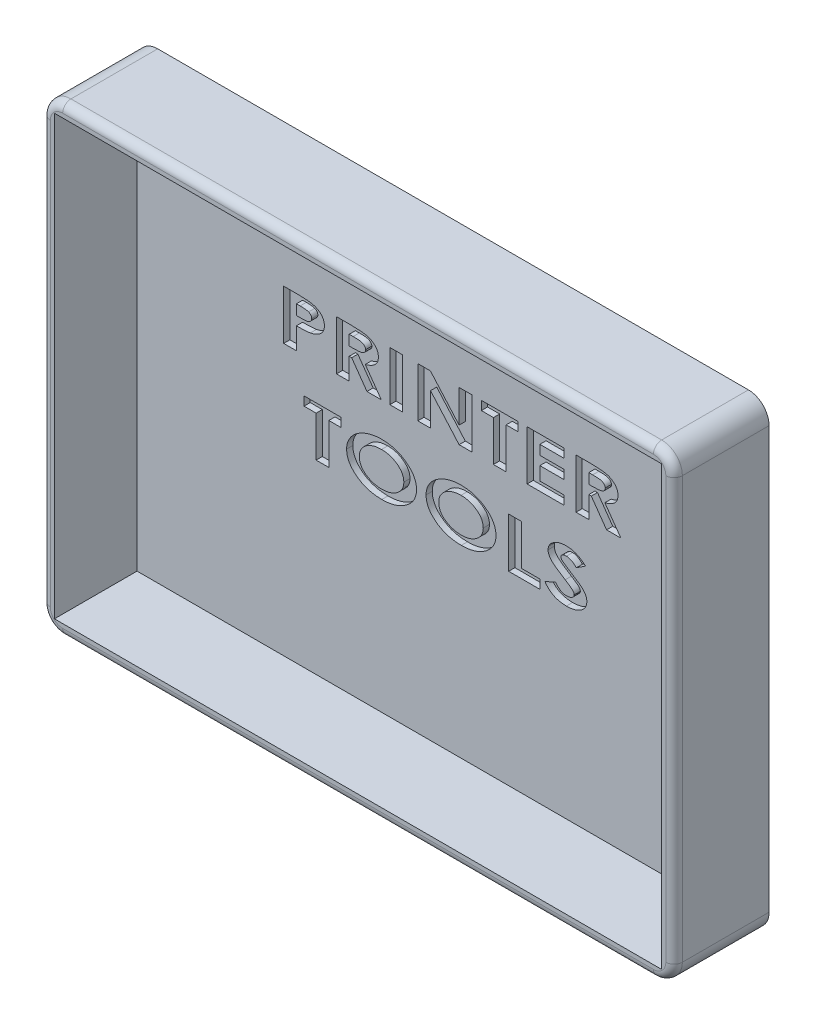
from build123d import *

# Parameters (mm, degrees)
SKETCH1_W           = 153
SKETCH1_H           = 112
BOSS_EXTRUDE1_DEPTH = 3
SKETCH1_3_W         = 153
SKETCH1_3_H         = 112
SKETCH1_3_W_2       = 147
SKETCH1_3_H_2       = 106
BOSS_EXTRUDE2_DEPTH = 23
FILLET2_R           = 5
SKETCH2_W           = 3.076923077
SKETCH2_H           = 12
CUT_EXTRUDE1_DEPTH  = 1.5
FILLET3_R           = 2


with BuildPart() as part:
    # Sketch1 → Boss-Extrude1 (new body)
    with BuildSketch(Plane.XY):
        with Locations((30.305422648, -30.684210526)):
            Rectangle(SKETCH1_W, SKETCH1_H)
    extrude(amount=BOSS_EXTRUDE1_DEPTH)

    # Sketch1_3 → Boss-Extrude2 (add)
    with BuildSketch(Plane.XY):
        with Locations((30.305422648, -30.684210526)):
            Rectangle(SKETCH1_3_W, SKETCH1_3_H)
        with Locations((30.305422648, -30.684210526)):
            Rectangle(SKETCH1_3_W_2, SKETCH1_3_H_2, mode=Mode.SUBTRACT)
    extrude(amount=BOSS_EXTRUDE2_DEPTH)

    # Fillet2
    fillet2_edges = [part.edges().sort_by_distance(p)[0] for p in [
        (-46.194577352, -86.684210526, 11.5),
        (106.805422648, -86.684210526, 11.5),
        (106.805422648, 25.315789474, 11.5),
        (-46.194577352, 25.315789474, 11.5),
    ]]
    fillet(fillet2_edges, radius=FILLET2_R)

    # Sketch2 → Cut-Extrude1 (cut)
    # profile 1 of 12: a face of its own
    with BuildSketch(Plane.XY.offset(3)):
        with BuildLine():
            Line((-7.695579614, -6.197177574), (-4.349425768, -6.197177574))
            add(Edge.make_bspline(
                [(-4.349425768, -6.197177574), (-4.131467614, -6.197879272), (-3.710704223, -6.199233883), (-3.103144005, -6.215737304), (-2.542184607, -6.245066636), (-2.028928537, -6.281485518), (-1.563280857, -6.332664074), (-1.145069661, -6.390836776), (-0.773328843, -6.462155499), (-0.443402082, -6.546890093), (-0.145691957, -6.645697252), (0.13296354, -6.75186301), (0.391506905, -6.879711466), (0.639402349, -7.011764168), (0.867025458, -7.165496853), (1.082376086, -7.327943018), (1.280194507, -7.506561053), (1.460170342, -7.699443536), (1.623579223, -7.901540289), (1.764138864, -8.116214552), (1.885557013, -8.338851141), (1.980483241, -8.57435743), (2.059592806, -8.817132684), (2.110378509, -9.072176501), (2.14653073, -9.335561495), (2.149217666, -9.515157797), (2.150574232, -9.605831421)],
                knots=[0, 0, 0, 0, 1.900234888, 3.668361378, 5.29824944, 6.797419469, 8.153669347, 9.381710471, 10.477773137, 11.452059101, 12.348987854, 13.211691364, 14.049075643, 14.861973494, 15.658312658, 16.440772353, 17.212397831, 17.97846912, 18.738913567, 19.475196238, 20.212836479, 20.945830748, 21.685980875, 22.435435663, 23.210091095, 24, 24, 24, 24], degree=3))
            add(Edge.make_bspline(
                [(2.150574232, -9.605831421), (2.147867067, -9.706142994), (2.14253497, -9.903719033), (2.098514921, -10.193181857), (2.025408944, -10.469052156), (1.927374553, -10.733721068), (1.796727947, -10.984401602), (1.635891414, -11.220560789), (1.450806817, -11.446839604), (1.232122761, -11.654005562), (0.993171391, -11.850703825), (0.732492987, -12.031275679), (0.451674064, -12.195227151), (0.150370942, -12.344333507), (-0.171973476, -12.478137466), (-0.514236551, -12.59900067), (-0.877154686, -12.702489054), (-1.127929291, -12.756302871), (-1.255675768, -12.783716036)],
                knots=[0, 0, 0, 0, 0.947754169, 1.866718941, 2.759471002, 3.641428849, 4.528897163, 5.423702711, 6.338100003, 7.286096209, 8.26548705, 9.261284238, 10.279606345, 11.336321123, 12.436199946, 13.576329595, 14.765363998, 16, 16, 16, 16], degree=3))
            add(Edge.make_bspline(
                [(-1.255675768, -12.783716036), (-1.340477898, -12.799027687), (-1.524578479, -12.832268408), (-1.827368136, -12.865930289), (-2.176819972, -12.896773674), (-2.573515238, -12.923387066), (-3.017588279, -12.941492092), (-3.508811633, -12.955576697), (-4.048101182, -12.965867911), (-4.42313843, -12.966223148), (-4.618656537, -12.966408344)],
                knots=[0, 0, 0, 0, 0.613221355, 1.331268544, 2.167268072, 3.11042782, 4.160855784, 5.330565642, 6.608344223, 8, 8, 8, 8], degree=3))
            Line((-4.618656537, -12.966408344), (-4.618656537, -18.197177574))
            Line((-4.618656537, -18.197177574), (-7.695579614, -18.197177574))
            Line((-7.695579614, -18.197177574), (-7.695579614, -6.197177574))
        make_face()
        with BuildLine():
            Line((-4.618656537, -10.81256219), (-3.601829614, -10.81256219))
            add(Edge.make_bspline(
                [(-3.601829614, -10.81256219), (-3.505674623, -10.81190457), (-3.320564917, -10.810638575), (-3.054482429, -10.806522541), (-2.810794726, -10.797259626), (-2.591280496, -10.782388183), (-2.393910615, -10.766556965), (-2.220093442, -10.744477948), (-2.068075558, -10.722000712), (-1.900023268, -10.68381989), (-1.71561963, -10.623717561), (-1.516550116, -10.532578797), (-1.341649369, -10.422057161), (-1.192825623, -10.291539877), (-1.073675701, -10.142147718), (-0.988040191, -9.97559123), (-0.935356602, -9.794087059), (-0.929394202, -9.667886041), (-0.926348845, -9.603427574)],
                knots=[0, 0, 0, 0, 1.407605413, 2.709806541, 3.895428679, 4.976847854, 5.930489772, 6.793236331, 7.541454841, 8.178861105, 9.313911922, 10.374001262, 11.376181959, 12.331769573, 13.258707867, 14.155775968, 15.058043621, 16, 16, 16, 16], degree=3))
            add(Edge.make_bspline(
                [(-0.926348845, -9.603427574), (-0.928471644, -9.54711837), (-0.932612279, -9.437284214), (-0.970356718, -9.279286589), (-1.028595595, -9.132252483), (-1.110291405, -8.995622574), (-1.221245851, -8.875329604), (-1.35317864, -8.767095415), (-1.505363324, -8.665633721), (-1.620916995, -8.615263243), (-1.681156537, -8.589004497)],
                knots=[0, 0, 0, 0, 0.99967641, 1.949923027, 2.870450112, 3.803674722, 4.761895576, 5.763194509, 6.833925937, 8, 8, 8, 8], degree=3))
            add(Edge.make_bspline(
                [(-1.681156537, -8.589004497), (-1.731324429, -8.569628601), (-1.839554677, -8.527827799), (-2.021902872, -8.481533475), (-2.232300183, -8.441595142), (-2.472190478, -8.408067498), (-2.740886636, -8.382577432), (-3.039863219, -8.362761379), (-3.36781756, -8.354968555), (-3.596220318, -8.352371933), (-3.714810383, -8.351023728)],
                knots=[0, 0, 0, 0, 0.626672195, 1.351958081, 2.189428709, 3.123683958, 4.175242118, 5.336301276, 6.616968516, 8, 8, 8, 8], degree=3))
            Line((-3.714810383, -8.351023728), (-4.618656537, -8.351023728))
            Line((-4.618656537, -8.351023728), (-4.618656537, -10.81256219))
        make_face(mode=Mode.SUBTRACT)
    # profile 2 of 12: a face of its own
    with BuildSketch(Plane.XY.offset(3)):
        with BuildLine():
            Line((5.073651155, -6.197177574), (8.523170386, -6.197177574))
            add(Edge.make_bspline(
                [(8.523170386, -6.197177574), (8.750747746, -6.197791838), (9.189944995, -6.198977293), (9.822245411, -6.216587639), (10.404198058, -6.241837818), (10.934173925, -6.279274779), (11.414294904, -6.3299995), (11.84268897, -6.388597237), (12.221011719, -6.457127557), (12.553307177, -6.539597912), (12.853071694, -6.635819066), (13.132155907, -6.743071681), (13.395730781, -6.867200625), (13.645754459, -7.002715932), (13.88005405, -7.156183599), (14.101589864, -7.320642176), (14.306444855, -7.502497062), (14.496393324, -7.695965049), (14.666159414, -7.902339724), (14.817489389, -8.117536414), (14.944317635, -8.343139895), (15.049149765, -8.577855957), (15.12798197, -8.822345423), (15.186136709, -9.074740371), (15.220302505, -9.337270963), (15.225068935, -9.51518749), (15.227497309, -9.605831421)],
                knots=[0, 0, 0, 0, 1.942360821, 3.748525479, 5.398471571, 6.913875045, 8.282418781, 9.518505043, 10.603687565, 11.562434919, 12.438404284, 13.289346962, 14.112375837, 14.923468866, 15.714505135, 16.50100498, 17.276273883, 18.050093459, 18.812802014, 19.554618987, 20.292643093, 21.018300149, 21.744987786, 22.48161628, 23.226422243, 24, 24, 24, 24], degree=3))
            add(Edge.make_bspline(
                [(15.227497309, -9.605831421), (15.225573315, -9.700544367), (15.221790142, -9.886779562), (15.180516871, -10.159143314), (15.122397007, -10.420785255), (15.034552049, -10.67051461), (14.921479656, -10.907565453), (14.785335619, -11.134301168), (14.624537546, -11.348132952), (14.436590288, -11.548176294), (14.227969781, -11.739725288), (13.98926994, -11.914577474), (13.72869362, -12.080069114), (13.441297744, -12.232366032), (13.130259804, -12.372724383), (12.794193473, -12.503125017), (12.433103425, -12.621235868), (12.181397835, -12.687272166), (12.05201654, -12.721216036)],
                knots=[0, 0, 0, 0, 0.938261817, 1.844915378, 2.725580461, 3.592377074, 4.462987792, 5.325404772, 6.21039484, 7.109815044, 8.043390327, 9.01418199, 10.039020095, 11.101679491, 12.235815788, 13.420467275, 14.674072806, 16, 16, 16, 16], degree=3))
            Line((12.05201654, -12.721216036), (15.919805001, -18.197177574))
            Line((15.919805001, -18.197177574), (12.45826654, -18.197177574))
            Line((12.45826654, -18.197177574), (8.763555001, -12.966408344))
            Line((8.763555001, -12.966408344), (8.150574232, -12.966408344))
            Line((8.150574232, -12.966408344), (8.150574232, -18.197177574))
            Line((8.150574232, -18.197177574), (5.073651155, -18.197177574))
            Line((5.073651155, -18.197177574), (5.073651155, -6.197177574))
        make_face()
        with BuildLine():
            Line((8.150574232, -10.81256219), (9.23951654, -10.81256219))
            add(Edge.make_bspline(
                [(9.23951654, -10.81256219), (9.372531557, -10.811391488), (9.628201298, -10.809141269), (9.995495867, -10.799031275), (10.329710072, -10.774191883), (10.631112904, -10.743044672), (10.901353531, -10.706992837), (11.138617554, -10.655935328), (11.345067184, -10.599783582), (11.520849134, -10.532313803), (11.670876876, -10.454106745), (11.799967238, -10.365862854), (11.906982056, -10.26229608), (11.99797672, -10.149816306), (12.06484483, -10.021599637), (12.116430185, -9.884788226), (12.145525221, -9.734440986), (12.148848811, -9.630793321), (12.150574232, -9.576985267)],
                knots=[0, 0, 0, 0, 1.810256827, 3.479516111, 4.999140943, 6.369538748, 7.603227407, 8.706779841, 9.669889474, 10.512282949, 11.263419155, 11.968249844, 12.631536789, 13.283796803, 13.92780119, 14.590191195, 15.26810634, 16, 16, 16, 16], degree=3))
            add(Edge.make_bspline(
                [(12.150574232, -9.576985267), (12.146934721, -9.513266081), (12.139729467, -9.387119225), (12.079850272, -9.204648904), (11.977294657, -9.039151196), (11.841577785, -8.886809693), (11.671922737, -8.753586805), (11.476344592, -8.6379508), (11.254154619, -8.543636331), (11.04774873, -8.483925714), (10.858680195, -8.447132546), (10.687997821, -8.420391064), (10.490511398, -8.40022932), (10.266226497, -8.38020044), (10.014478821, -8.366596105), (9.735580177, -8.356991674), (9.429431164, -8.352946507), (9.216279633, -8.351683625), (9.104901155, -8.351023728)],
                knots=[0, 0, 0, 0, 0.842981993, 1.668877706, 2.511859699, 3.406725258, 4.358415719, 5.357990113, 6.409063649, 7.547987131, 8.197583625, 8.96033808, 9.836107581, 10.827075533, 11.943612093, 13.175842126, 14.52428738, 16, 16, 16, 16], degree=3))
            Line((9.104901155, -8.351023728), (8.150574232, -8.351023728))
            Line((8.150574232, -8.351023728), (8.150574232, -10.81256219))
        make_face(mode=Mode.SUBTRACT)
    # profile 3 of 12: a face of its own
    with BuildSketch(Plane.XY.offset(3)):
        with Locations((19.535189616, -12.197177574)):
            Rectangle(SKETCH2_W, SKETCH2_H)
    # profile 4 of 12: a face of its own
    with BuildSketch(Plane.XY.offset(3)):
        Polygon((24.765958848, -6.197177574), (27.828458848, -6.197177574), (34.765958848, -14.09381219), (34.765958848, -6.197177574), (37.842881924, -6.197177574), (37.842881924, -18.197177574), (34.761151155, -18.197177574), (27.842881924, -10.324581421), (27.842881924, -18.197177574), (24.765958848, -18.197177574), align=None)
    # profile 5 of 12: a face of its own
    with BuildSketch(Plane.XY.offset(3)):
        Polygon((40.150574232, -6.197177574), (49.073651155, -6.197177574), (49.073651155, -8.351023728), (46.150574232, -8.351023728), (46.150574232, -18.197177574), (43.073651155, -18.197177574), (43.073651155, -8.351023728), (40.150574232, -8.351023728), align=None)
    # profile 6 of 12: a face of its own
    with BuildSketch(Plane.XY.offset(3)):
        Polygon((51.227497309, -6.197177574), (60.150574232, -6.197177574), (60.150574232, -8.351023728), (54.304420386, -8.351023728), (54.304420386, -10.658716036), (60.150574232, -10.658716036), (60.150574232, -12.81256219), (54.304420386, -12.81256219), (54.304420386, -16.043331421), (60.150574232, -16.043331421), (60.150574232, -18.197177574), (51.227497309, -18.197177574), align=None)
    # profile 7 of 12: a face of its own
    with BuildSketch(Plane.XY.offset(3)):
        with BuildLine():
            Line((63.073651155, -6.197177574), (66.523170386, -6.197177574))
            add(Edge.make_bspline(
                [(66.523170386, -6.197177574), (66.750747746, -6.197791838), (67.189944995, -6.198977293), (67.822245411, -6.216587639), (68.404198058, -6.241837818), (68.934173925, -6.279274779), (69.414294904, -6.3299995), (69.84268897, -6.388597237), (70.221011719, -6.457127557), (70.553307177, -6.539597912), (70.853071694, -6.635819066), (71.132155907, -6.743071681), (71.395730781, -6.867200625), (71.645754459, -7.002715932), (71.88005405, -7.156183599), (72.101589864, -7.320642176), (72.306444855, -7.502497062), (72.496393324, -7.695965049), (72.666159414, -7.902339724), (72.817489389, -8.117536414), (72.944317635, -8.343139895), (73.049149765, -8.577855957), (73.12798197, -8.822345423), (73.186136709, -9.074740371), (73.220302505, -9.337270963), (73.225068935, -9.51518749), (73.227497309, -9.605831421)],
                knots=[0, 0, 0, 0, 1.942360821, 3.748525479, 5.398471571, 6.913875045, 8.282418781, 9.518505043, 10.603687565, 11.562434919, 12.438404284, 13.289346962, 14.112375837, 14.923468866, 15.714505135, 16.50100498, 17.276273883, 18.050093459, 18.812802014, 19.554618987, 20.292643093, 21.018300149, 21.744987786, 22.48161628, 23.226422243, 24, 24, 24, 24], degree=3))
            add(Edge.make_bspline(
                [(73.227497309, -9.605831421), (73.225573315, -9.700544367), (73.221790142, -9.886779562), (73.180516871, -10.159143314), (73.122397007, -10.420785255), (73.034552049, -10.67051461), (72.921479656, -10.907565453), (72.785335619, -11.134301168), (72.624537546, -11.348132952), (72.436590288, -11.548176294), (72.227969781, -11.739725288), (71.98926994, -11.914577474), (71.72869362, -12.080069114), (71.441297744, -12.232366032), (71.130259804, -12.372724383), (70.794193473, -12.503125017), (70.433103425, -12.621235868), (70.181397835, -12.687272166), (70.05201654, -12.721216036)],
                knots=[0, 0, 0, 0, 0.938261817, 1.844915378, 2.725580461, 3.592377074, 4.462987792, 5.325404772, 6.21039484, 7.109815044, 8.043390327, 9.01418199, 10.039020095, 11.101679491, 12.235815788, 13.420467275, 14.674072806, 16, 16, 16, 16], degree=3))
            Line((70.05201654, -12.721216036), (73.919805001, -18.197177574))
            Line((73.919805001, -18.197177574), (70.45826654, -18.197177574))
            Line((70.45826654, -18.197177574), (66.763555001, -12.966408344))
            Line((66.763555001, -12.966408344), (66.150574232, -12.966408344))
            Line((66.150574232, -12.966408344), (66.150574232, -18.197177574))
            Line((66.150574232, -18.197177574), (63.073651155, -18.197177574))
            Line((63.073651155, -18.197177574), (63.073651155, -6.197177574))
        make_face()
        with BuildLine():
            Line((66.150574232, -10.81256219), (67.23951654, -10.81256219))
            add(Edge.make_bspline(
                [(67.23951654, -10.81256219), (67.372531557, -10.811391488), (67.628201298, -10.809141269), (67.995495867, -10.799031275), (68.329710072, -10.774191883), (68.631112904, -10.743044672), (68.901353531, -10.706992837), (69.138617554, -10.655935328), (69.345067184, -10.599783582), (69.520849134, -10.532313803), (69.670876876, -10.454106745), (69.799967238, -10.365862854), (69.906982056, -10.26229608), (69.99797672, -10.149816306), (70.06484483, -10.021599637), (70.116430185, -9.884788226), (70.145525221, -9.734440986), (70.148848811, -9.630793321), (70.150574232, -9.576985267)],
                knots=[0, 0, 0, 0, 1.810256827, 3.479516111, 4.999140943, 6.369538748, 7.603227407, 8.706779841, 9.669889474, 10.512282949, 11.263419155, 11.968249844, 12.631536789, 13.283796803, 13.92780119, 14.590191195, 15.26810634, 16, 16, 16, 16], degree=3))
            add(Edge.make_bspline(
                [(70.150574232, -9.576985267), (70.146934721, -9.513266081), (70.139729467, -9.387119225), (70.079850272, -9.204648904), (69.977294657, -9.039151196), (69.841577785, -8.886809693), (69.671922737, -8.753586805), (69.476344592, -8.6379508), (69.254154619, -8.543636331), (69.04774873, -8.483925714), (68.858680195, -8.447132546), (68.687997821, -8.420391064), (68.490511398, -8.40022932), (68.266226497, -8.38020044), (68.014478821, -8.366596105), (67.735580177, -8.356991674), (67.429431164, -8.352946507), (67.216279633, -8.351683625), (67.104901155, -8.351023728)],
                knots=[0, 0, 0, 0, 0.842981993, 1.668877706, 2.511859699, 3.406725258, 4.358415719, 5.357990113, 6.409063649, 7.547987131, 8.197583625, 8.96033808, 9.836107581, 10.827075533, 11.943612093, 13.175842126, 14.52428738, 16, 16, 16, 16], degree=3))
            Line((67.104901155, -8.351023728), (66.150574232, -8.351023728))
            Line((66.150574232, -8.351023728), (66.150574232, -10.81256219))
        make_face(mode=Mode.SUBTRACT)
    # profile 8 of 12: a face of its own
    with BuildSketch(Plane.XY.offset(3)):
        Polygon((-2.772502691, -26.735639113), (6.150574232, -26.735639113), (6.150574232, -28.889485267), (3.227497309, -28.889485267), (3.227497309, -38.735639113), (0.150574232, -38.735639113), (0.150574232, -28.889485267), (-2.772502691, -28.889485267), align=None)
    # profile 9 of 12: a face of its own
    with BuildSketch(Plane.XY.offset(3)):
        with BuildLine():
            add(Edge.make_bspline(
                [(16.030381924, -26.427946805), (16.313464778, -26.433281266), (16.870571184, -26.443779472), (17.690963054, -26.5329144), (18.481204957, -26.675715702), (19.241728769, -26.878399254), (19.972107481, -27.138030614), (20.671919756, -27.45627568), (21.340498516, -27.833436075), (21.869213507, -28.192318047), (22.270223583, -28.503427209), (22.553061142, -28.742643209), (22.817568613, -28.98847452), (23.058165861, -29.24357625), (23.284960994, -29.50105028), (23.487793817, -29.768178464), (23.674085875, -30.03914507), (23.83831577, -30.318428594), (23.984650192, -30.602122767), (24.110273204, -30.894070572), (24.219263457, -31.190423495), (24.304606965, -31.495567081), (24.375906418, -31.804798328), (24.422896601, -32.121509006), (24.452916801, -32.444187071), (24.456472288, -32.661853115), (24.45826654, -32.771696805)],
                knots=[0, 0, 0, 0, 1.745145968, 3.434443253, 5.081950776, 6.692722788, 8.282073641, 9.856384965, 11.427133449, 13.009958241, 13.791714529, 14.555942899, 15.293528752, 16.016945007, 16.717403943, 17.408176707, 18.083798791, 18.743904067, 19.404619276, 20.050801644, 20.702570137, 21.350035736, 22.003319428, 22.658077529, 23.322807938, 24, 24, 24, 24], degree=3))
            add(Edge.make_bspline(
                [(24.45826654, -32.771696805), (24.456431295, -32.879933089), (24.452781447, -33.095188341), (24.4231306, -33.41473388), (24.375076142, -33.728632526), (24.307854016, -34.036194142), (24.221500795, -34.337470758), (24.11412709, -34.631247779), (23.993010172, -34.920914226), (23.847646653, -35.202081437), (23.68321935, -35.476968838), (23.501027681, -35.74648464), (23.297437111, -36.007995723), (23.079325664, -36.266954139), (22.83820868, -36.516378949), (22.577499668, -36.758431505), (22.301189718, -36.998262679), (21.904185796, -37.303552621), (21.380308733, -37.657536546), (20.717030226, -38.030199798), (20.018899219, -38.342797499), (19.289070242, -38.600626648), (18.525976508, -38.800505741), (17.730155684, -38.941290676), (16.901648051, -39.026773345), (16.338279239, -39.037752579), (16.05201654, -39.043331421)],
                knots=[0, 0, 0, 0, 0.67051785, 1.33349449, 1.986488314, 2.636986177, 3.282787654, 3.926658881, 4.573985186, 5.226771377, 5.885776778, 6.557745033, 7.240935207, 7.938283214, 8.654566243, 9.388675605, 10.142022968, 10.920566582, 12.49030535, 14.055074537, 15.628326538, 17.223646782, 18.845680182, 20.509983457, 22.226629637, 24, 24, 24, 24], degree=3))
            add(Edge.make_bspline(
                [(16.05201654, -39.043331421), (15.900544408, -39.042015286), (15.601449642, -39.039416466), (15.157333914, -39.016639141), (14.723299595, -38.982352438), (14.29878103, -38.927388005), (13.883924116, -38.864043877), (13.477972734, -38.784508352), (13.082635251, -38.688734428), (12.697468317, -38.5770564), (12.320533169, -38.455261382), (11.954110932, -38.315998386), (11.597350632, -38.161644366), (11.250736639, -37.993412074), (10.913535786, -37.80973356), (10.584592343, -37.613892777), (10.266598213, -37.40136395), (9.960618094, -37.176285062), (9.667798131, -36.942271246), (9.394229627, -36.698316612), (9.136411199, -36.45244259), (8.89981289, -36.198008763), (8.681160711, -35.939215208), (8.481182038, -35.674490538), (8.300524533, -35.404880429), (8.138302401, -35.130007259), (7.996841722, -34.848669565), (7.873598445, -34.562209481), (7.770696499, -34.270298441), (7.683149261, -33.973801893), (7.615209749, -33.671189819), (7.571334787, -33.362408064), (7.540351627, -33.048765672), (7.536921163, -32.837479417), (7.535189617, -32.730831421)],
                knots=[0, 0, 0, 0, 1.23785739, 2.444256004, 3.633631352, 4.795169465, 5.941806634, 7.063009603, 8.174840564, 9.265073711, 10.339876336, 11.411402117, 12.467345856, 13.515871935, 14.559067395, 15.604664997, 16.643576268, 17.683560242, 18.708340531, 19.705742031, 20.67834854, 21.618923025, 22.543772652, 23.446185256, 24.32889845, 25.1948367, 26.05293937, 26.900785464, 27.741724346, 28.581004192, 29.426266696, 30.273682739, 31.128631069, 32, 32, 32, 32], degree=3))
            add(Edge.make_bspline(
                [(7.535189617, -32.730831421), (7.538218692, -32.588838737), (7.544246865, -32.30625862), (7.59903142, -31.887159115), (7.687503626, -31.476781898), (7.814199881, -31.076066737), (7.973004646, -30.683680124), (8.166138604, -30.298534378), (8.39810017, -29.924345425), (8.662928876, -29.55927496), (8.956548652, -29.207129875), (9.281254584, -28.874722628), (9.629819601, -28.559158128), (10.005841321, -28.263005687), (10.409082755, -27.986854231), (10.83639334, -27.726098054), (11.293114556, -27.489182168), (11.771767827, -27.268783692), (12.267966627, -27.069972998), (12.77821213, -26.899772162), (13.296543007, -26.75149063), (13.826179081, -26.636045258), (14.363026135, -26.539678598), (14.910674039, -26.477344547), (15.46716189, -26.433411743), (15.841992403, -26.429774753), (16.030381924, -26.427946805)],
                knots=[0, 0, 0, 0, 0.873545157, 1.738445156, 2.596414495, 3.454256273, 4.321472879, 5.199225574, 6.102525423, 7.027795969, 7.97301071, 8.9215899, 9.885252081, 10.86491977, 11.864845162, 12.891577554, 13.943741457, 15.029372765, 16.133759519, 17.231619976, 18.338470262, 19.449968713, 20.566368297, 21.693693259, 22.840852048, 24, 24, 24, 24], degree=3))
        make_face()
        with BuildLine():
            add(Edge.make_bspline(
                [(15.984708848, -28.581792959), (15.798664494, -28.585484814), (15.433748369, -28.592726192), (14.897931864, -28.649692853), (14.383981684, -28.739545725), (13.892808566, -28.869655269), (13.42418118, -29.036295377), (12.977399751, -29.237527466), (12.555449674, -29.480237743), (12.158525109, -29.753754529), (11.797667104, -30.056896154), (11.478669015, -30.381468598), (11.214337738, -30.730826295), (10.990837574, -31.095171308), (10.822848879, -31.484404984), (10.699361714, -31.89130087), (10.625335191, -32.319492029), (10.616574228, -32.611150206), (10.612112694, -32.759677574)],
                knots=[0, 0, 0, 0, 1.177915509, 2.310418757, 3.408289834, 4.479079589, 5.523885619, 6.554848934, 7.57758788, 8.602288603, 9.603464323, 10.55798171, 11.477463708, 12.372050713, 13.258222719, 14.153960245, 15.059901456, 16, 16, 16, 16], degree=3))
            add(Edge.make_bspline(
                [(10.612112694, -32.759677574), (10.618067804, -32.924382439), (10.629782516, -33.248384868), (10.723711871, -33.719983827), (10.875125811, -34.165928341), (11.093285608, -34.582900519), (11.368526149, -34.975968487), (11.710414375, -35.337174585), (12.10900324, -35.674682905), (12.409353971, -35.867240454), (12.564035771, -35.966408344)],
                knots=[0, 0, 0, 0, 1.002378203, 1.971848096, 2.916297197, 3.86133863, 4.827991989, 5.829253018, 6.882056827, 8, 8, 8, 8], degree=3))
            add(Edge.make_bspline(
                [(12.564035771, -35.966408344), (12.691121383, -36.040628983), (12.945806324, -36.189370281), (13.348271744, -36.374528715), (13.763078942, -36.53460972), (14.192221937, -36.664338114), (14.634860942, -36.765125226), (15.091776278, -36.837186599), (15.562358019, -36.881359014), (15.88124752, -36.88675723), (16.042401155, -36.889485267)],
                knots=[0, 0, 0, 0, 0.968643878, 1.941203282, 2.913290218, 3.894783287, 4.890638372, 5.900389362, 6.938943154, 8, 8, 8, 8], degree=3))
            add(Edge.make_bspline(
                [(16.042401155, -36.889485267), (16.223622619, -36.885663384), (16.580510815, -36.878136765), (17.105510693, -36.822524238), (17.60998348, -36.728178372), (18.094591068, -36.599355349), (18.558111965, -36.430701449), (18.999764687, -36.222423419), (19.421792613, -35.978660933), (19.820392002, -35.702976267), (20.184284806, -35.397948228), (20.502400908, -35.07022298), (20.775617275, -34.727033751), (20.998114189, -34.364924313), (21.171777987, -33.984080387), (21.289627031, -33.584823761), (21.369108379, -33.169869126), (21.377223027, -32.886658573), (21.381343463, -32.742850651)],
                knots=[0, 0, 0, 0, 1.159372101, 2.283207576, 3.373194553, 4.440212365, 5.487928247, 6.524559945, 7.560443406, 8.602890401, 9.621657833, 10.593309606, 11.520501184, 12.422635105, 13.306015146, 14.189915719, 15.080880085, 16, 16, 16, 16], degree=3))
            add(Edge.make_bspline(
                [(21.381343463, -32.742850651), (21.377086026, -32.599876429), (21.368678457, -32.317531558), (21.290800583, -31.903475326), (21.16812403, -31.506260833), (20.995998697, -31.125489667), (20.772518474, -30.762572189), (20.498305562, -30.417984647), (20.176313602, -30.090048861), (19.810104827, -29.782999995), (19.410202056, -29.501167176), (18.98267574, -29.256573832), (18.536474662, -29.04409342), (18.065839087, -28.877955483), (17.575734725, -28.745041421), (17.064821348, -28.64823004), (16.531600093, -28.593204661), (16.16912827, -28.585641146), (15.984708848, -28.581792959)],
                knots=[0, 0, 0, 0, 0.90719629, 1.791527272, 2.665475917, 3.542279041, 4.437696418, 5.365131948, 6.333100567, 7.351453338, 8.396138617, 9.435668054, 10.475956939, 11.53022765, 12.60045266, 13.698266854, 14.828917806, 16, 16, 16, 16], degree=3))
        make_face(mode=Mode.SUBTRACT)
    # profile 10 of 12: a face of its own
    with BuildSketch(Plane.XY.offset(3)):
        with BuildLine():
            add(Edge.make_bspline(
                [(35.261151155, -26.427946805), (35.544234009, -26.433281266), (36.101340414, -26.443779472), (36.921732285, -26.5329144), (37.711974187, -26.675715702), (38.472498, -26.878399254), (39.202876712, -27.138030614), (39.902688987, -27.45627568), (40.571267747, -27.833436075), (41.099982738, -28.192318047), (41.500992813, -28.503427209), (41.783830372, -28.742643209), (42.048337844, -28.98847452), (42.288935092, -29.24357625), (42.515730225, -29.50105028), (42.718563048, -29.768178464), (42.904855106, -30.03914507), (43.069085, -30.318428594), (43.215419423, -30.602122767), (43.341042435, -30.894070572), (43.450032687, -31.190423495), (43.535376196, -31.495567081), (43.606675649, -31.804798328), (43.653665831, -32.121509006), (43.683686031, -32.444187071), (43.687241518, -32.661853115), (43.689035771, -32.771696805)],
                knots=[0, 0, 0, 0, 1.745145968, 3.434443253, 5.081950776, 6.692722788, 8.282073641, 9.856384965, 11.427133449, 13.009958241, 13.791714529, 14.555942899, 15.293528752, 16.016945007, 16.717403943, 17.408176707, 18.083798791, 18.743904067, 19.404619276, 20.050801644, 20.702570137, 21.350035736, 22.003319428, 22.658077529, 23.322807938, 24, 24, 24, 24], degree=3))
            add(Edge.make_bspline(
                [(43.689035771, -32.771696805), (43.687200526, -32.879933089), (43.683550678, -33.095188341), (43.653899831, -33.41473388), (43.605845373, -33.728632526), (43.538623247, -34.036194142), (43.452270026, -34.337470758), (43.344896321, -34.631247779), (43.223779403, -34.920914226), (43.078415884, -35.202081437), (42.913988581, -35.476968838), (42.731796912, -35.74648464), (42.528206342, -36.007995723), (42.310094895, -36.266954139), (42.068977911, -36.516378949), (41.808268899, -36.758431505), (41.531958949, -36.998262679), (41.134955027, -37.303552621), (40.611077964, -37.657536546), (39.947799456, -38.030199798), (39.24966845, -38.342797499), (38.519839473, -38.600626648), (37.756745739, -38.800505741), (36.960924915, -38.941290676), (36.132417281, -39.026773345), (35.56904847, -39.037752579), (35.282785771, -39.043331421)],
                knots=[0, 0, 0, 0, 0.67051785, 1.33349449, 1.986488314, 2.636986177, 3.282787654, 3.926658881, 4.573985186, 5.226771377, 5.885776778, 6.557745033, 7.240935207, 7.938283214, 8.654566243, 9.388675605, 10.142022968, 10.920566582, 12.49030535, 14.055074537, 15.628326538, 17.223646782, 18.845680182, 20.509983457, 22.226629637, 24, 24, 24, 24], degree=3))
            add(Edge.make_bspline(
                [(35.282785771, -39.043331421), (35.131313639, -39.042015286), (34.832218873, -39.039416466), (34.388103144, -39.016639141), (33.954068825, -38.982352438), (33.529550261, -38.927388005), (33.114693347, -38.864043877), (32.708741965, -38.784508352), (32.313404481, -38.688734428), (31.928237547, -38.5770564), (31.5513024, -38.455261382), (31.184880163, -38.315998386), (30.828119862, -38.161644366), (30.48150587, -37.993412074), (30.144305016, -37.80973356), (29.815361573, -37.613892777), (29.497367444, -37.40136395), (29.191387325, -37.176285062), (28.898567362, -36.942271246), (28.624998858, -36.698316612), (28.36718043, -36.45244259), (28.13058212, -36.198008763), (27.911929942, -35.939215208), (27.711951269, -35.674490538), (27.531293764, -35.404880429), (27.369071632, -35.130007259), (27.227610953, -34.848669565), (27.104367675, -34.562209481), (27.00146573, -34.270298441), (26.913918491, -33.973801893), (26.84597898, -33.671189819), (26.802104018, -33.362408064), (26.771120857, -33.048765672), (26.767690394, -32.837479417), (26.765958848, -32.730831421)],
                knots=[0, 0, 0, 0, 1.23785739, 2.444256004, 3.633631352, 4.795169465, 5.941806634, 7.063009603, 8.174840564, 9.265073711, 10.339876336, 11.411402117, 12.467345856, 13.515871935, 14.559067395, 15.604664997, 16.643576268, 17.683560242, 18.708340531, 19.705742031, 20.67834854, 21.618923025, 22.543772652, 23.446185256, 24.32889845, 25.1948367, 26.05293937, 26.900785464, 27.741724346, 28.581004192, 29.426266696, 30.273682739, 31.128631069, 32, 32, 32, 32], degree=3))
            add(Edge.make_bspline(
                [(26.765958848, -32.730831421), (26.768987923, -32.588838737), (26.775016095, -32.30625862), (26.829800651, -31.887159115), (26.918272857, -31.476781898), (27.044969112, -31.076066737), (27.203773877, -30.683680124), (27.396907835, -30.298534378), (27.628869401, -29.924345425), (27.893698107, -29.55927496), (28.187317882, -29.207129875), (28.512023815, -28.874722628), (28.860588832, -28.559158128), (29.236610552, -28.263005687), (29.639851986, -27.986854231), (30.067162571, -27.726098054), (30.523883787, -27.489182168), (31.002537057, -27.268783692), (31.498735858, -27.069972998), (32.008981361, -26.899772162), (32.527312238, -26.75149063), (33.056948312, -26.636045258), (33.593795366, -26.539678598), (34.14144327, -26.477344547), (34.697931121, -26.433411743), (35.072761634, -26.429774753), (35.261151155, -26.427946805)],
                knots=[0, 0, 0, 0, 0.873545157, 1.738445156, 2.596414495, 3.454256273, 4.321472879, 5.199225574, 6.102525423, 7.027795969, 7.97301071, 8.9215899, 9.885252081, 10.86491977, 11.864845162, 12.891577554, 13.943741457, 15.029372765, 16.133759519, 17.231619976, 18.338470262, 19.449968713, 20.566368297, 21.693693259, 22.840852048, 24, 24, 24, 24], degree=3))
        make_face()
        with BuildLine():
            add(Edge.make_bspline(
                [(35.215478078, -28.581792959), (35.029433725, -28.585484814), (34.6645176, -28.592726192), (34.128701095, -28.649692853), (33.614750915, -28.739545725), (33.123577796, -28.869655269), (32.65495041, -29.036295377), (32.208168982, -29.237527466), (31.786218904, -29.480237743), (31.38929434, -29.753754529), (31.028436334, -30.056896154), (30.709438246, -30.381468598), (30.445106969, -30.730826295), (30.221606805, -31.095171308), (30.05361811, -31.484404984), (29.930130944, -31.89130087), (29.856104422, -32.319492029), (29.847343458, -32.611150206), (29.842881924, -32.759677574)],
                knots=[0, 0, 0, 0, 1.177915509, 2.310418757, 3.408289834, 4.479079589, 5.523885619, 6.554848934, 7.57758788, 8.602288603, 9.603464323, 10.55798171, 11.477463708, 12.372050713, 13.258222719, 14.153960245, 15.059901456, 16, 16, 16, 16], degree=3))
            add(Edge.make_bspline(
                [(29.842881924, -32.759677574), (29.848837034, -32.924382439), (29.860551747, -33.248384868), (29.954481101, -33.719983827), (30.105895041, -34.165928341), (30.324054839, -34.582900519), (30.59929538, -34.975968487), (30.941183606, -35.337174585), (31.339772471, -35.674682905), (31.640123202, -35.867240454), (31.794805001, -35.966408344)],
                knots=[0, 0, 0, 0, 1.002378203, 1.971848096, 2.916297197, 3.86133863, 4.827991989, 5.829253018, 6.882056827, 8, 8, 8, 8], degree=3))
            add(Edge.make_bspline(
                [(31.794805001, -35.966408344), (31.921890614, -36.040628983), (32.176575554, -36.189370281), (32.579040975, -36.374528715), (32.993848173, -36.53460972), (33.422991167, -36.664338114), (33.865630172, -36.765125226), (34.322545509, -36.837186599), (34.79312725, -36.881359014), (35.11201675, -36.88675723), (35.273170386, -36.889485267)],
                knots=[0, 0, 0, 0, 0.968643878, 1.941203282, 2.913290218, 3.894783287, 4.890638372, 5.900389362, 6.938943154, 8, 8, 8, 8], degree=3))
            add(Edge.make_bspline(
                [(35.273170386, -36.889485267), (35.454391849, -36.885663384), (35.811280046, -36.878136765), (36.336279924, -36.822524238), (36.840752711, -36.728178372), (37.325360298, -36.599355349), (37.788881196, -36.430701449), (38.230533918, -36.222423419), (38.652561844, -35.978660933), (39.051161233, -35.702976267), (39.415054036, -35.397948228), (39.733170139, -35.07022298), (40.006386506, -34.727033751), (40.22888342, -34.364924313), (40.402547218, -33.984080387), (40.520396262, -33.584823761), (40.599877609, -33.169869126), (40.607992258, -32.886658573), (40.612112694, -32.742850651)],
                knots=[0, 0, 0, 0, 1.159372101, 2.283207576, 3.373194553, 4.440212365, 5.487928247, 6.524559945, 7.560443406, 8.602890401, 9.621657833, 10.593309606, 11.520501184, 12.422635105, 13.306015146, 14.189915719, 15.080880085, 16, 16, 16, 16], degree=3))
            add(Edge.make_bspline(
                [(40.612112694, -32.742850651), (40.607855256, -32.599876429), (40.599447687, -32.317531558), (40.521569814, -31.903475326), (40.398893261, -31.506260833), (40.226767928, -31.125489667), (40.003287705, -30.762572189), (39.729074793, -30.417984647), (39.407082833, -30.090048861), (39.040874058, -29.782999995), (38.640971287, -29.501167176), (38.213444971, -29.256573832), (37.767243893, -29.04409342), (37.296608317, -28.877955483), (36.806503956, -28.745041421), (36.295590579, -28.64823004), (35.762369323, -28.593204661), (35.399897501, -28.585641146), (35.215478078, -28.581792959)],
                knots=[0, 0, 0, 0, 0.90719629, 1.791527272, 2.665475917, 3.542279041, 4.437696418, 5.365131948, 6.333100567, 7.351453338, 8.396138617, 9.435668054, 10.475956939, 11.53022765, 12.60045266, 13.698266854, 14.828917806, 16, 16, 16, 16], degree=3))
        make_face(mode=Mode.SUBTRACT)
    # profile 11 of 12: a face of its own
    with BuildSketch(Plane.XY.offset(3)):
        Polygon((46.765958848, -26.735639113), (49.842881924, -26.735639113), (49.842881924, -36.581792959), (54.304420386, -36.581792959), (54.304420386, -38.735639113), (46.765958848, -38.735639113), align=None)
    # profile 12 of 12: a face of its own
    with BuildSketch(Plane.XY.offset(3)):
        with BuildLine():
            Line((65.381343463, -28.339004497), (63.138555001, -29.81256219))
            add(Edge.make_bspline(
                [(63.138555001, -29.81256219), (63.04150607, -29.714798462), (62.853056187, -29.524960584), (62.553888707, -29.275125463), (62.255498501, -29.06189481), (61.955484812, -28.88590353), (61.652117546, -28.75088003), (61.347519364, -28.653882504), (61.041625307, -28.592936274), (60.836743413, -28.585497561), (60.734708848, -28.581792959)],
                knots=[0, 0, 0, 0, 1.190525164, 2.311765056, 3.36520098, 4.358604661, 5.313879002, 6.229751941, 7.118387239, 8, 8, 8, 8], degree=3))
            add(Edge.make_bspline(
                [(60.734708848, -28.581792959), (60.639962883, -28.584134284), (60.458071822, -28.588629103), (60.198147421, -28.634564571), (59.964822693, -28.711442778), (59.761773422, -28.815353603), (59.597486774, -28.938359696), (59.472105783, -29.06957603), (59.396941537, -29.215888732), (59.386434982, -29.318247279), (59.381343463, -29.367850651)],
                knots=[0, 0, 0, 0, 1.330159043, 2.553607876, 3.692836374, 4.770373652, 5.743066602, 6.563974043, 7.304095923, 8, 8, 8, 8], degree=3))
            add(Edge.make_bspline(
                [(59.381343463, -29.367850651), (59.384702079, -29.417929589), (59.391533409, -29.519788753), (59.445225529, -29.669464411), (59.533831701, -29.812625469), (59.612167585, -29.897929308), (59.652978078, -29.942369882)],
                knots=[0, 0, 0, 0, 0.920298768, 1.871862052, 2.891308131, 4, 4, 4, 4], degree=3))
            add(Edge.make_bspline(
                [(59.652978078, -29.942369882), (59.690945204, -29.977414044), (59.77970591, -30.059341355), (59.94639861, -30.183704996), (60.153600047, -30.340907878), (60.410413619, -30.520510463), (60.712131034, -30.727011659), (61.062494002, -30.956704892), (61.45546125, -31.217886415), (61.735978372, -31.396406949), (61.883747309, -31.490446805)],
                knots=[0, 0, 0, 0, 0.45603203, 1.0661256, 1.834627495, 2.75350167, 3.833023019, 5.063610394, 6.45318828, 8, 8, 8, 8], degree=3))
            add(Edge.make_bspline(
                [(61.883747309, -31.490446805), (62.021551506, -31.57781088), (62.282886176, -31.743489882), (62.65409419, -31.97829451), (62.980326252, -32.191343317), (63.266879939, -32.374045075), (63.507208066, -32.53683895), (63.707451731, -32.671161612), (63.865482244, -32.779666616), (63.954433213, -32.846778712), (63.991920386, -32.87506219)],
                knots=[0, 0, 0, 0, 1.552293685, 2.943801188, 4.178653364, 5.259149018, 6.176746603, 6.940011425, 7.553282258, 8, 8, 8, 8], degree=3))
            add(Edge.make_bspline(
                [(63.991920386, -32.87506219), (64.136289026, -32.989179486), (64.411000718, -33.206327445), (64.774662748, -33.546976003), (65.073331276, -33.879409996), (65.304969959, -34.211157518), (65.476077062, -34.547837571), (65.602197744, -34.893255423), (65.675160024, -35.255811178), (65.68438706, -35.502952684), (65.689035771, -35.627466036)],
                knots=[0, 0, 0, 0, 1.312468895, 2.497429846, 3.550423517, 4.495533471, 5.375034974, 6.237577385, 7.112066805, 8, 8, 8, 8], degree=3))
            add(Edge.make_bspline(
                [(65.689035771, -35.627466036), (65.685139355, -35.748796138), (65.677469098, -35.98763954), (65.608781453, -36.336846005), (65.505504297, -36.671461822), (65.34965369, -36.986256474), (65.156346781, -37.287775852), (64.916936682, -37.570950706), (64.634317381, -37.83689703), (64.314051683, -38.084989885), (63.958876326, -38.30977484), (63.575532469, -38.507689012), (63.165018343, -38.6736639), (62.727938832, -38.807614333), (62.265840621, -38.9127577), (61.777704262, -38.989866011), (61.263649227, -39.035921234), (60.91188773, -39.04082694), (60.732305001, -39.043331421)],
                knots=[0, 0, 0, 0, 0.868811549, 1.71029202, 2.542211582, 3.371927485, 4.219482013, 5.104152839, 6.022326931, 6.99656169, 8.003564138, 9.031077577, 10.084838529, 11.1730359, 12.304379326, 13.479039229, 14.712988716, 16, 16, 16, 16], degree=3))
            add(Edge.make_bspline(
                [(60.732305001, -39.043331421), (60.591229611, -39.041529638), (60.312785042, -39.037973407), (59.902008155, -39.00847032), (59.504802962, -38.960876667), (59.121935305, -38.893768807), (58.752782733, -38.806942137), (58.396977163, -38.70164641), (58.054919467, -38.57648063), (57.726091492, -38.431953613), (57.410460227, -38.265598273), (57.106846278, -38.077648702), (56.815393046, -37.867897548), (56.535000739, -37.635902772), (56.267135965, -37.381050944), (56.008152989, -37.106130512), (55.762715542, -36.807924226), (55.61165921, -36.595552424), (55.535189617, -36.488042959)],
                knots=[0, 0, 0, 0, 1.118567985, 2.207749923, 3.263810248, 4.289619113, 5.288307529, 6.26935655, 7.230197879, 8.174681463, 9.115438921, 10.05701139, 11.003928279, 11.960643095, 12.940456797, 13.933876122, 14.954061372, 16, 16, 16, 16], degree=3))
            Line((55.535189617, -36.488042959), (58.097689617, -35.351023728))
            add(Edge.make_bspline(
                [(58.097689617, -35.351023728), (58.194082726, -35.473074484), (58.380785111, -35.709472784), (58.687942281, -36.023059995), (59.00369043, -36.290907528), (59.332525075, -36.509502797), (59.673315692, -36.679397866), (60.025438041, -36.800836275), (60.388589329, -36.875801391), (60.634999473, -36.884910598), (60.758747309, -36.889485267)],
                knots=[0, 0, 0, 0, 1.168605251, 2.263454204, 3.293961514, 4.276421015, 5.224765032, 6.148763627, 7.070304121, 8, 8, 8, 8], degree=3))
            add(Edge.make_bspline(
                [(60.758747309, -36.889485267), (60.884905293, -36.885831297), (61.127810124, -36.878795936), (61.475799947, -36.810926181), (61.795140345, -36.708574122), (62.072435248, -36.555379848), (62.308616767, -36.38490158), (62.479765685, -36.188523797), (62.592586334, -35.977197853), (62.605667833, -35.82664091), (62.612112694, -35.752466036)],
                knots=[0, 0, 0, 0, 1.271814217, 2.448753583, 3.56637365, 4.641061586, 5.634205734, 6.488609534, 7.255383409, 8, 8, 8, 8], degree=3))
            add(Edge.make_bspline(
                [(62.612112694, -35.752466036), (62.607654365, -35.683622204), (62.598464863, -35.541721365), (62.513190654, -35.334325278), (62.3861919, -35.126582241), (62.236906914, -34.959531248), (62.08586138, -34.818342011), (61.938512336, -34.697225731), (61.763359044, -34.559355188), (61.555567892, -34.411871869), (61.319676986, -34.247674983), (61.053222951, -34.069885619), (60.754709337, -33.881046107), (60.545683695, -33.750738109), (60.436631924, -33.682754497)],
                knots=[0, 0, 0, 0, 0.794434314, 1.637487225, 2.562413113, 3.608512959, 4.219241158, 4.95728375, 5.816984293, 6.801079997, 7.908280076, 9.146584944, 10.511331137, 12, 12, 12, 12], degree=3))
            add(Edge.make_bspline(
                [(60.436631924, -33.682754497), (60.228810658, -33.553411975), (59.830024252, -33.305217743), (59.262422456, -32.941731534), (58.754195732, -32.596814214), (58.302758724, -32.276729591), (57.909852303, -31.978548626), (57.573857559, -31.704439254), (57.294291747, -31.454467233), (57.06819343, -31.220750193), (56.887394366, -30.996375895), (56.731488316, -30.778639265), (56.598962834, -30.561563613), (56.492403805, -30.342237445), (56.406850336, -30.12498415), (56.350044442, -29.906056334), (56.311270756, -29.688938331), (56.306694569, -29.543495406), (56.304420386, -29.471216036)],
                knots=[0, 0, 0, 0, 1.916196781, 3.676973209, 5.275785729, 6.723906262, 8.008545569, 9.136149616, 10.117571378, 10.942733828, 11.678437588, 12.371144969, 13.038098532, 13.6664772, 14.278038524, 14.862291426, 15.434603922, 16, 16, 16, 16], degree=3))
            add(Edge.make_bspline(
                [(56.304420386, -29.471216036), (56.307827282, -29.368347173), (56.314568425, -29.164803037), (56.377480053, -28.865398353), (56.479029828, -28.577891381), (56.62002929, -28.301703376), (56.800519428, -28.037280894), (57.020744277, -27.784037569), (57.282479266, -27.544157952), (57.57916092, -27.317032122), (57.905736643, -27.111072896), (58.252817934, -26.926456622), (58.620336854, -26.773269908), (59.005720516, -26.645023003), (59.410274549, -26.547124555), (59.83287547, -26.477518754), (60.273957748, -26.436494953), (60.574365846, -26.430832971), (60.727497309, -26.427946805)],
                knots=[0, 0, 0, 0, 0.832202766, 1.646659515, 2.465524548, 3.295498105, 4.150387516, 5.051997593, 6.007082385, 7.020705296, 8.073791693, 9.130350931, 10.200531492, 11.294237454, 12.416370906, 13.567418749, 14.760004378, 16, 16, 16, 16], degree=3))
            add(Edge.make_bspline(
                [(60.727497309, -26.427946805), (60.926478212, -26.433038864), (61.320329141, -26.443117782), (61.90344648, -26.523439533), (62.472127312, -26.649054249), (62.9348875, -26.801718785), (63.302481429, -26.950860067), (63.584091762, -27.086038503), (63.869807724, -27.244173297), (64.164244291, -27.417473367), (64.459029054, -27.620903793), (64.764664171, -27.836932277), (65.072820585, -28.079328174), (65.276870666, -28.251072244), (65.381343463, -28.339004497)],
                knots=[0, 0, 0, 0, 1.389820793, 2.750928363, 4.10510972, 5.45420087, 6.149736827, 6.875939553, 7.635083208, 8.431051425, 9.261799364, 10.136509639, 11.045900652, 12, 12, 12, 12], degree=3))
        make_face()
    extrude(amount=-CUT_EXTRUDE1_DEPTH, mode=Mode.SUBTRACT)

    # Fillet3
    fillet3_edges = [part.edges().sort_by_distance(p)[0] for p in [
        (-44.730111258, -85.219744432, 23),
        (-46.194577352, -30.684210526, 23),
        (-44.730111258, 23.85132338, 23),
        (30.305422648, 25.315789474, 23),
        (105.340956553, 23.85132338, 23),
        (106.805422648, -30.684210526, 23),
        (105.340956553, -85.219744432, 23),
        (30.305422648, -86.684210526, 23),
    ]]
    fillet(fillet3_edges, radius=FILLET3_R)


solid = part.part
